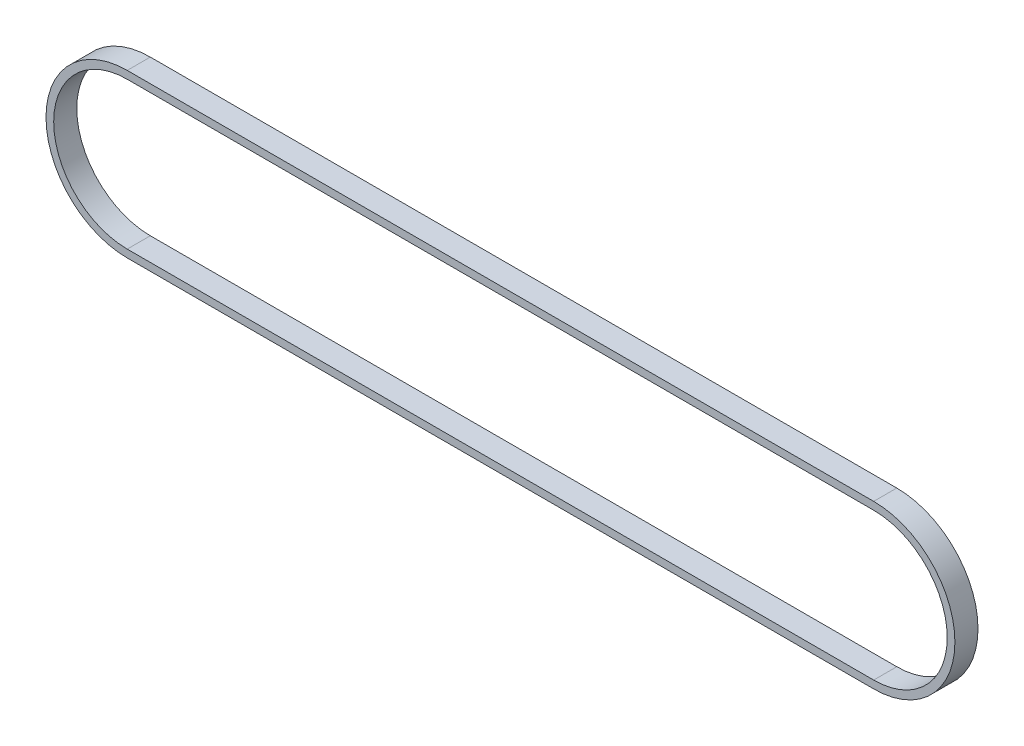
from build123d import *

# Parameters (mm, degrees)
BOSS_EXTRUDE1_DEPTH = 6


with BuildPart() as part:
    # Sketch1 → Boss-Extrude1 (new body)
    with BuildSketch(Plane.XY):
        with BuildLine():
            Line((194, -21.11), (0, -21.11))
            ThreePointArc((0, -21.11), (-21.11, 0), (0, 21.11))
            Line((0, 21.11), (194, 21.11))
            ThreePointArc((194, 21.11), (215.11, 0), (194, -21.11))
        make_face()
        with BuildLine():
            Line((0, 19.11), (194, 19.11))
            ThreePointArc((194, 19.11), (213.11, 0), (194, -19.11))
            Line((194, -19.11), (0, -19.11))
            ThreePointArc((0, -19.11), (-19.11, 0), (0, 19.11))
        make_face(mode=Mode.SUBTRACT)
    extrude(amount=BOSS_EXTRUDE1_DEPTH)


solid = part.part
